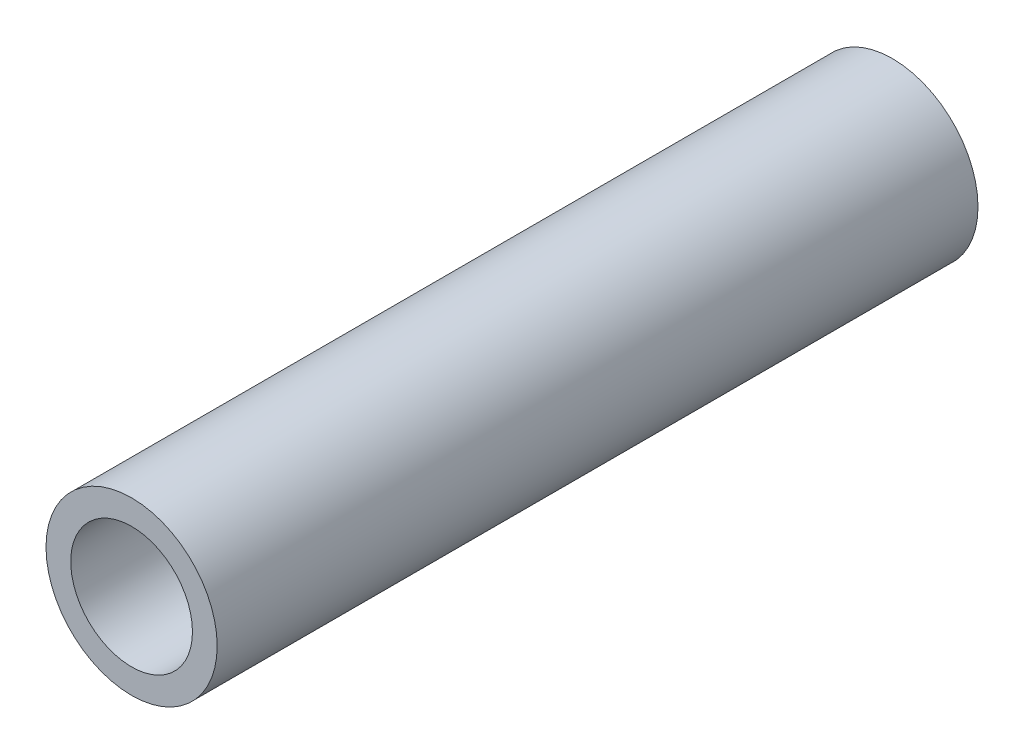
from build123d import *

# Parameters (mm, degrees)
SKETCH1_R      = 2.25
SKETCH1_R_2    = 1.6
EXTRUDE1_DEPTH = 10


with BuildPart() as part:
    # Sketch1 → Extrude1 (new body, symmetric)
    with BuildSketch(Plane.XY):
        Circle(SKETCH1_R)
        Circle(SKETCH1_R_2, mode=Mode.SUBTRACT)
    extrude(amount=EXTRUDE1_DEPTH, both=True)


solid = part.part
